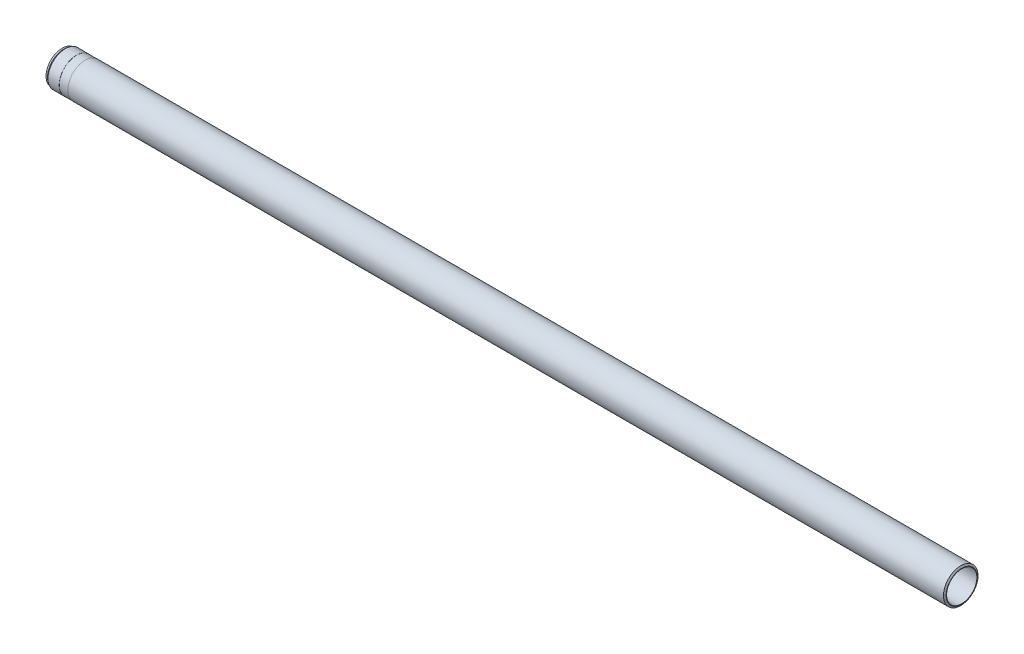
from build123d import *


with BuildPart() as part:
    # Sketch1 → Base-Revolve (revolve)
    with BuildSketch(Plane.XY):
        Polygon((0, 35), (0, 36), (-2.309401077, 40), (-2028, 40), (-2028, 39.75), (-2048, 39.75), (-2048, 40), (-2073.929629983, 40), (-2077.5, 37.5), (-2081, 37.5), (-2081, 35.727350269), (-2080, 35.15), (-2066, 35.15), (-2065.740192379, 35), align=None)
    revolve(axis=Axis((-122.784188742, 0, 0), (1, 0, 0)))


solid = part.part
